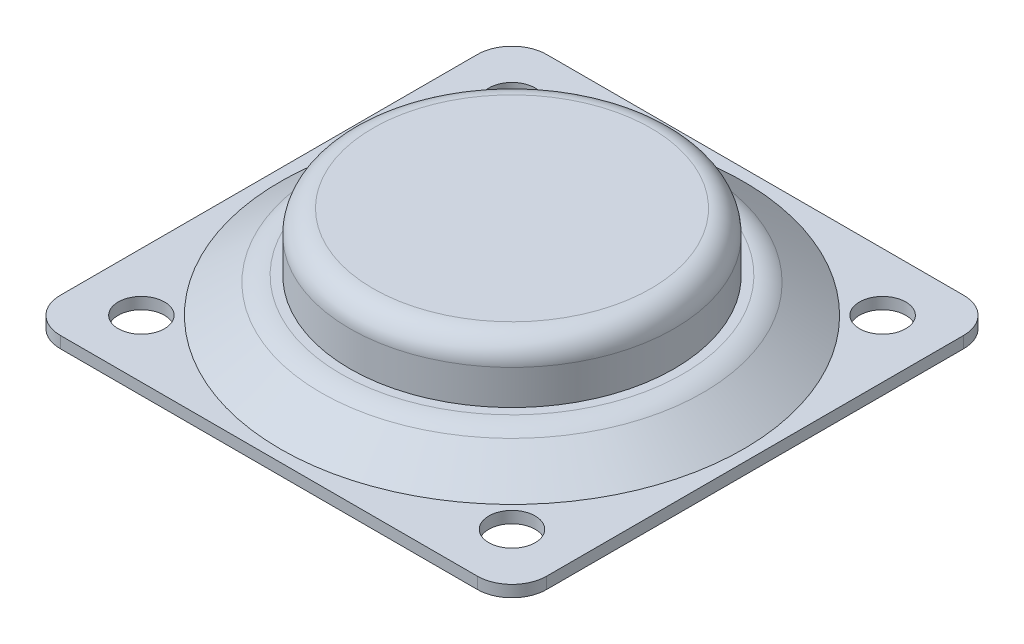
from build123d import *

# Parameters (mm, degrees)
ESQUISSE1_W             = 42
ESQUISSE1_H             = 42
BOSS_EXTRU_1_DEPTH      = 1
CONG_1_R                = 3
ENL_V_MAT_EXTRU_1_REACH = 11
ESQUISSE3_R             = 2


with BuildPart() as part:
    # Esquisse1 → Boss.-Extru.1 (new body)
    with BuildSketch(Plane(origin=(0, 0, 0), x_dir=(1, 0, 0), z_dir=(0, 1, 0))):
        Rectangle(ESQUISSE1_W, ESQUISSE1_H)
    extrude(amount=BOSS_EXTRU_1_DEPTH)

    # Congé1
    cong_1_edges = [part.edges().sort_by_distance(p)[0] for p in [
        (-21, 0.5, -21),
        (21, 0.5, -21),
        (21, 0.5, 21),
        (-21, 0.5, 21),
    ]]
    fillet(cong_1_edges, radius=CONG_1_R)

    # Esquisse2 → Révolution1 (revolve)
    with BuildSketch(Plane(origin=(0, 0, 0), x_dir=(0, 0, -1), z_dir=(1, 0, 0))):
        with BuildLine():
            Line((-20, 1), (-16.490388922, 3.457456133))
            ThreePointArc((-16.490388922, 3.457456133), (-15.671777012, 3.861150852), (-14.769659613, 4))
            Line((-14.769659613, 4), (-14, 4))
            Line((-14, 4), (-14, 7))
            ThreePointArc((-14, 7), (-13.414213562, 8.414213562), (-12, 9))
            Line((-12, 9), (0, 9))
            Line((0, 9), (0, 4))
            Line((0, 4), (0, 1))
            Line((0, 1), (-20, 1))
        make_face()
    revolve(axis=Axis((0, 4, 0), (0, -1, 0)))

    # Esquisse3 → Enlèv. mat.-Extru.1 (cut, up to next)
    with BuildSketch(Plane.XZ, mode=Mode.PRIVATE) as enl_v_mat_extru_1_sk1:
        with Locations((-16, 16)):
            Circle(ESQUISSE3_R)
    enl_v_mat_extru_1_tool1 = extrude(enl_v_mat_extru_1_sk1.sketch, amount=-ENL_V_MAT_EXTRU_1_REACH, mode=Mode.PRIVATE) & part.part
    add(enl_v_mat_extru_1_tool1.solids().sort_by_distance((-16, 0, 16))[0], mode=Mode.SUBTRACT)
    # Esquisse3 → Enlèv. mat.-Extru.1 (cut, up to next)
    with BuildSketch(Plane.XZ, mode=Mode.PRIVATE) as enl_v_mat_extru_1_sk2:
        with Locations((16, 16)):
            Circle(ESQUISSE3_R)
    enl_v_mat_extru_1_tool2 = extrude(enl_v_mat_extru_1_sk2.sketch, amount=-ENL_V_MAT_EXTRU_1_REACH, mode=Mode.PRIVATE) & part.part
    add(enl_v_mat_extru_1_tool2.solids().sort_by_distance((16, 0, 16))[0], mode=Mode.SUBTRACT)
    # Esquisse3 → Enlèv. mat.-Extru.1 (cut, up to next)
    with BuildSketch(Plane.XZ, mode=Mode.PRIVATE) as enl_v_mat_extru_1_sk3:
        with Locations((-16, -16)):
            Circle(ESQUISSE3_R)
    enl_v_mat_extru_1_tool3 = extrude(enl_v_mat_extru_1_sk3.sketch, amount=-ENL_V_MAT_EXTRU_1_REACH, mode=Mode.PRIVATE) & part.part
    add(enl_v_mat_extru_1_tool3.solids().sort_by_distance((-16, 0, -16))[0], mode=Mode.SUBTRACT)
    # Esquisse3 → Enlèv. mat.-Extru.1 (cut, up to next)
    with BuildSketch(Plane.XZ, mode=Mode.PRIVATE) as enl_v_mat_extru_1_sk4:
        with Locations((16, -16)):
            Circle(ESQUISSE3_R)
    enl_v_mat_extru_1_tool4 = extrude(enl_v_mat_extru_1_sk4.sketch, amount=-ENL_V_MAT_EXTRU_1_REACH, mode=Mode.PRIVATE) & part.part
    add(enl_v_mat_extru_1_tool4.solids().sort_by_distance((16, 0, -16))[0], mode=Mode.SUBTRACT)


solid = part.part
